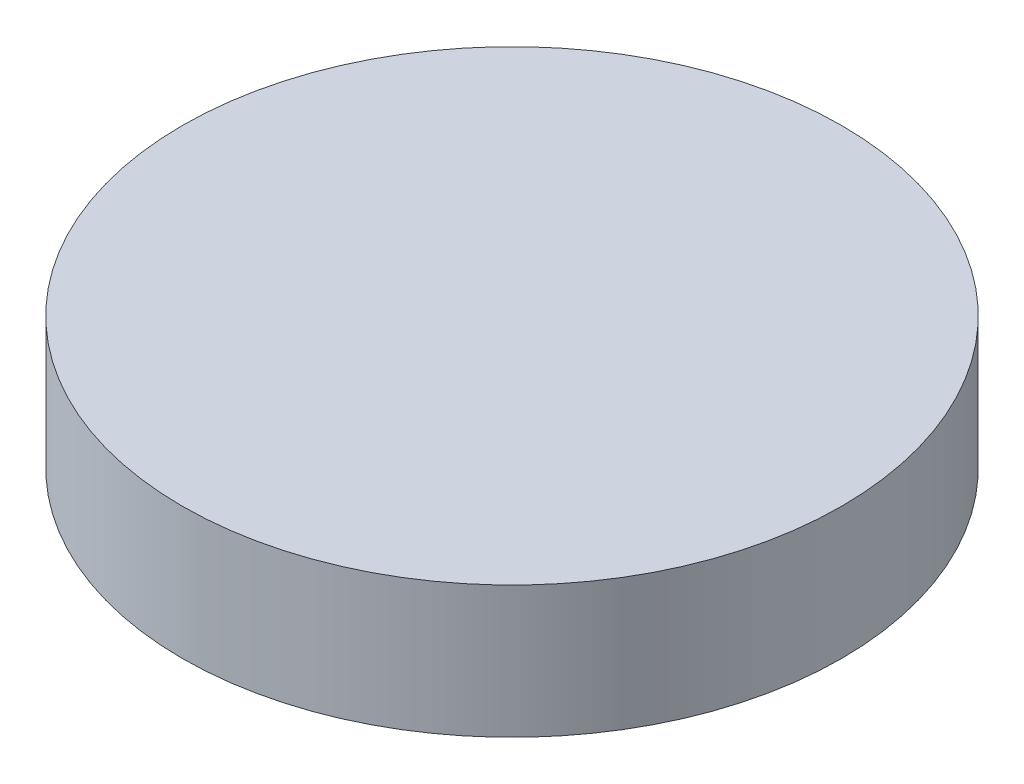
from build123d import *

# Parameters (mm, degrees)
SKETCH1_R           = 31.75
BOSS_EXTRUDE1_DEPTH = 12.7
SKETCH2_R           = 5.588
BOSS_EXTRUDE2_DEPTH = 12.7


with BuildPart() as part:
    # Sketch1 → Boss-Extrude1 (new body)
    with BuildSketch(Plane(origin=(0, 0, 0), x_dir=(1, 0, 0), z_dir=(0, 1, 0))):
        Circle(SKETCH1_R)
    extrude(amount=BOSS_EXTRUDE1_DEPTH)

    # Sketch2 → Boss-Extrude2 (add)
    with BuildSketch(Plane.XZ):
        Circle(SKETCH2_R)
    extrude(amount=BOSS_EXTRUDE2_DEPTH)


solid = part.part
